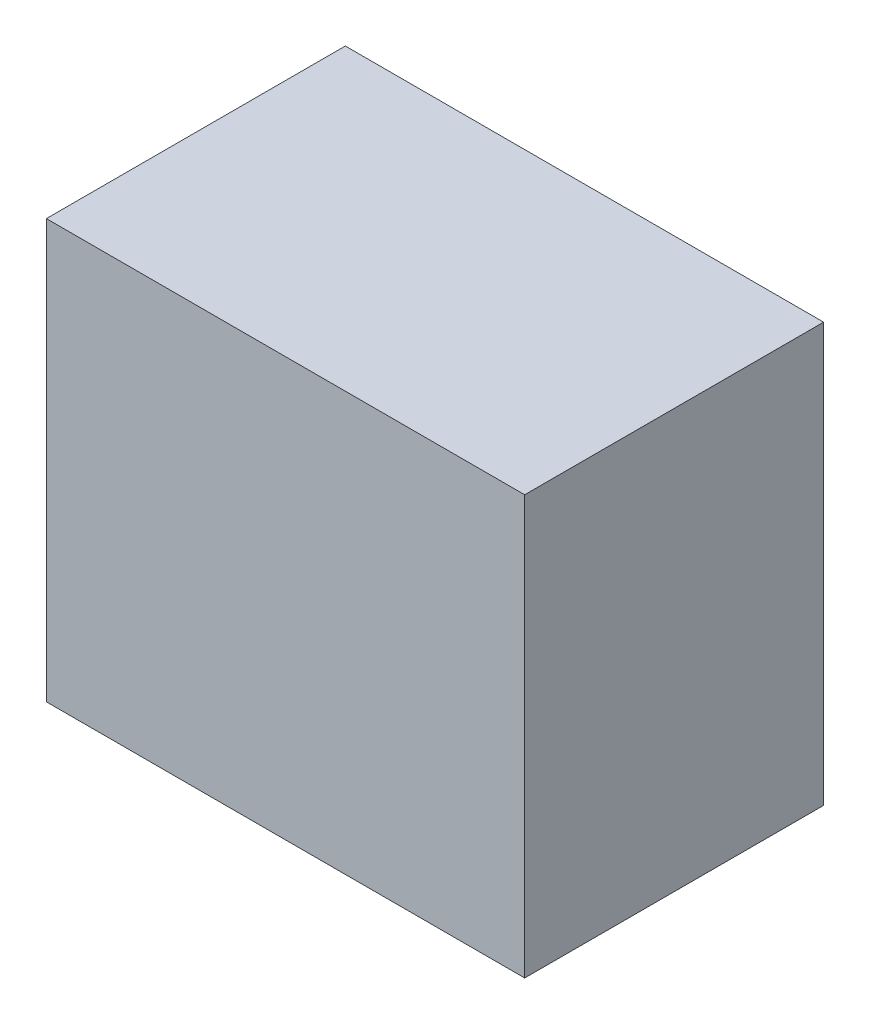
from build123d import *

# Parameters (mm, degrees)
SKETCH1_W           = 50.8
SKETCH1_H           = 44.45
BOSS_EXTRUDE1_DEPTH = 31.75


with BuildPart() as part:
    # Sketch1 → Boss-Extrude1 (new body)
    with BuildSketch(Plane.XY):
        with Locations((25.4, 22.225)):
            Rectangle(SKETCH1_W, SKETCH1_H)
    extrude(amount=BOSS_EXTRUDE1_DEPTH)


solid = part.part
